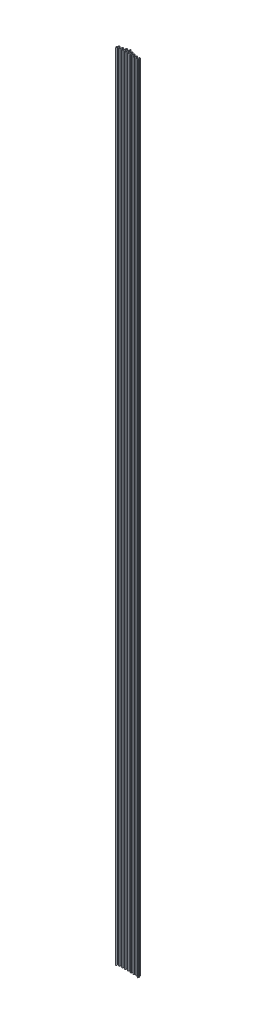
from build123d import *

# Parameters (mm, degrees)
BOSS_EXTRUDE1_DEPTH = 3505.2
CUT_EXTRUDE1_DEPTH  = 3506.2
BOSS_EXTRUDE2_DEPTH = 3505.2
FILLET1_R           = 0.508


with BuildPart() as part:
    # Sketch1 → Boss-Extrude1 (new body)
    with BuildSketch(Plane(origin=(0, 0, 0), x_dir=(1, 0, 0), z_dir=(0, 1, 0))):
        with BuildLine():
            Line((1.486485486, 1.007746677), (3.990499229, 7.290402101))
            ThreePointArc((3.990499229, 7.290402101), (6.35, 8.89), (8.709500771, 7.290402101))
            Line((8.709500771, 7.290402101), (11.213514514, 1.007746677))
            ThreePointArc((11.213514514, 1.007746677), (12.784145017, 0.002213875), (14.240485976, 1.167137652))
            Line((14.240485976, 1.167137652), (16.604784165, 9.577400553))
            ThreePointArc((16.604784165, 9.577400553), (19.05, 11.43), (21.495215835, 9.577400553))
            Line((21.495215835, 9.577400553), (23.859514024, 1.167137652))
            ThreePointArc((23.859514024, 1.167137652), (25.467277455, 0.001414904), (26.971422384, 1.298087881))
            Line((26.971422384, 1.298087881), (29.255678756, 13.179543046))
            ThreePointArc((29.255678756, 13.179543046), (31.75, 15.24), (34.244321244, 13.179543046))
            Line((34.244321244, 13.179543046), (36.528577616, 1.298087881))
            ThreePointArc((36.528577616, 1.298087881), (38.136521885, 0.00041683), (39.683572077, 1.370114107))
            Line((39.683572077, 1.370114107), (41.936393529, 16.875215703))
            ThreePointArc((41.936393529, 16.875215703), (44.45, 19.05), (46.963606471, 16.875215703))
            Line((46.963606471, 16.875215703), (49.216427923, 1.370114107))
            ThreePointArc((49.216427923, 1.370114107), (50.763478115, 0.00041683), (52.371422384, 1.298087881))
            Line((52.371422384, 1.298087881), (54.655678756, 13.179543046))
            ThreePointArc((54.655678756, 13.179543046), (57.15, 15.24), (59.644321244, 13.179543046))
            Line((59.644321244, 13.179543046), (61.928577616, 1.298087881))
            ThreePointArc((61.928577616, 1.298087881), (63.432722545, 0.001414904), (65.040485976, 1.167137652))
            Line((65.040485976, 1.167137652), (67.404784165, 9.577400553))
            ThreePointArc((67.404784165, 9.577400553), (69.85, 11.43), (72.295215835, 9.577400553))
            Line((72.295215835, 9.577400553), (74.659514024, 1.167137652))
            ThreePointArc((74.659514024, 1.167137652), (76.115854983, 0.002213875), (77.686485486, 1.007746677))
            Line((77.686485486, 1.007746677), (80.190499229, 7.290402101))
            ThreePointArc((80.190499229, 7.290402101), (82.55, 8.89), (84.909500771, 7.290402101))
            Line((84.909500771, 7.290402101), (87.413514514, 1.007746677))
            ThreePointArc((87.413514514, 1.007746677), (88.9, 0), (90.386485486, 1.007746677))
            Line((90.386485486, 1.007746677), (92.890499229, 7.290402101))
            ThreePointArc((92.890499229, 7.290402101), (95.25, 8.89), (97.609500771, 7.290402101))
            Line((97.609500771, 7.290402101), (100.113514514, 1.007746677))
            ThreePointArc((100.113514514, 1.007746677), (100.702058957, 0.275684268), (101.6, 0))
            Line((101.6, 0), (101.6, -1.524))
            ThreePointArc((101.6, -1.524), (99.846877012, -0.985759286), (98.697814051, 0.443505416))
            Line((98.697814051, 0.443505416), (96.193800308, 6.72616084))
            ThreePointArc((96.193800308, 6.72616084), (95.25, 7.366), (94.306199692, 6.72616084))
            Line((94.306199692, 6.72616084), (91.802185949, 0.443505416))
            ThreePointArc((91.802185949, 0.443505416), (88.9, -1.524), (85.997814051, 0.443505416))
            Line((85.997814051, 0.443505416), (83.493800308, 6.72616084))
            ThreePointArc((83.493800308, 6.72616084), (82.55, 7.366), (81.606199692, 6.72616084))
            Line((81.606199692, 6.72616084), (79.102185949, 0.443505416))
            ThreePointArc((79.102185949, 0.443505416), (76.035716871, -1.519677673), (73.192384523, 0.75469732))
            Line((73.192384523, 0.75469732), (70.828086334, 9.164960221))
            ThreePointArc((70.828086334, 9.164960221), (69.85, 9.906), (68.871913666, 9.164960221))
            Line((68.871913666, 9.164960221), (66.507615477, 0.75469732))
            ThreePointArc((66.507615477, 0.75469732), (63.368648778, -1.521237569), (60.43198487, 1.010362054))
            Line((60.43198487, 1.010362054), (58.147728498, 12.891817218))
            ThreePointArc((58.147728498, 12.891817218), (57.15, 13.716), (56.152271502, 12.891817218))
            Line((56.152271502, 12.891817218), (53.86801513, 1.010362054))
            ThreePointArc((53.86801513, 1.010362054), (50.728695368, -1.52318619), (47.708264041, 1.150984685))
            Line((47.708264041, 1.150984685), (45.455442588, 16.656086281))
            ThreePointArc((45.455442588, 16.656086281), (44.45, 17.526), (43.444557412, 16.656086281))
            Line((43.444557412, 16.656086281), (41.191735959, 1.150984685))
            ThreePointArc((41.191735959, 1.150984685), (38.171304632, -1.52318619), (35.03198487, 1.010362054))
            Line((35.03198487, 1.010362054), (32.747728498, 12.891817218))
            ThreePointArc((32.747728498, 12.891817218), (31.75, 13.716), (30.752271502, 12.891817218))
            Line((30.752271502, 12.891817218), (28.46801513, 1.010362054))
            ThreePointArc((28.46801513, 1.010362054), (25.531351222, -1.521237569), (22.392384523, 0.75469732))
            Line((22.392384523, 0.75469732), (20.028086334, 9.164960221))
            ThreePointArc((20.028086334, 9.164960221), (19.05, 9.906), (18.071913666, 9.164960221))
            Line((18.071913666, 9.164960221), (15.707615477, 0.75469732))
            ThreePointArc((15.707615477, 0.75469732), (12.864283129, -1.519677673), (9.797814051, 0.443505416))
            Line((9.797814051, 0.443505416), (7.293800308, 6.72616084))
            ThreePointArc((7.293800308, 6.72616084), (6.35, 7.366), (5.406199692, 6.72616084))
            Line((5.406199692, 6.72616084), (2.902185949, 0.443505416))
            ThreePointArc((2.902185949, 0.443505416), (1.753122988, -0.985759286), (0, -1.524))
            Line((0, -1.524), (0, 0))
            ThreePointArc((0, 0), (0.897941043, 0.275684268), (1.486485486, 1.007746677))
        make_face()
    extrude(amount=-BOSS_EXTRUDE1_DEPTH)

    # Sketch3 → Cut-Extrude1 (cut, through all)
    with BuildSketch(Plane(origin=(0, 0, 0), x_dir=(1, 0, 0), z_dir=(0, 1, 0))):
        Polygon((0, -0.762), (0, -1.524), (0.277345319, -1.524), align=None)
        Polygon((101.6, -0.762), (101.6, -1.524), (101.322654681, -1.524), align=None)
    extrude(amount=-CUT_EXTRUDE1_DEPTH, mode=Mode.SUBTRACT)

    # Sketch4 → Boss-Extrude2 (add, through all)
    with BuildSketch(Plane(origin=(0, 0, 0), x_dir=(1, 0, 0), z_dir=(0, 1, 0))):
        with BuildLine():
            Line((2.902185949, 0.443505416), (3.015459403, 0.727712357))
            ThreePointArc((3.015459403, 0.727712357), (3.040890247, 0.106552231), (3.520551169, -0.288937377))
            ThreePointArc((3.520551169, -0.288937377), (5.395968613, -3.748882593), (1.866026726, -5.488975049))
            ThreePointArc((1.866026726, -5.488975049), (1.726414147, -5.400370737), (1.63748848, -5.260962624))
            Line((1.63748848, -5.260962624), (1.411043325, -4.638809675))
            ThreePointArc((1.411043325, -4.638809675), (1.456969285, -4.289967378), (1.769066214, -4.1275))
            Line((1.769066214, -4.1275), (2.794, -4.1275))
            ThreePointArc((2.794, -4.1275), (4.0005, -2.921), (2.794, -1.7145))
            Line((2.794, -1.7145), (0.346681648, -1.7145))
            Line((0.346681648, -1.7145), (0.272995808, -1.512049818))
            ThreePointArc((0.272995808, -1.512049818), (1.864535831, -0.90661706), (2.902185949, 0.443505416))
        make_face()
        with BuildLine():
            Line((101.253318352, -1.7145), (101.327004192, -1.512049818))
            ThreePointArc((101.327004192, -1.512049818), (99.735464169, -0.90661706), (98.697814051, 0.443505416))
            Line((98.697814051, 0.443505416), (98.584540597, 0.727712357))
            ThreePointArc((98.584540597, 0.727712357), (98.559109753, 0.106552231), (98.079448831, -0.288937377))
            ThreePointArc((98.079448831, -0.288937377), (96.204031387, -3.748882593), (99.733973274, -5.488975049))
            ThreePointArc((99.733973274, -5.488975049), (99.873585853, -5.400370737), (99.96251152, -5.260962624))
            Line((99.96251152, -5.260962624), (100.188956675, -4.638809675))
            ThreePointArc((100.188956675, -4.638809675), (100.143030715, -4.289967378), (99.830933786, -4.1275))
            Line((99.830933786, -4.1275), (98.806, -4.1275))
            ThreePointArc((98.806, -4.1275), (97.5995, -2.921), (98.806, -1.7145))
            Line((98.806, -1.7145), (101.253318352, -1.7145))
        make_face()
    extrude(amount=-BOSS_EXTRUDE2_DEPTH)

    # Fillet1
    fillet1_edges = [part.edges().sort_by_distance(p)[0] for p in [
        (0.346681648, -1752.6, 1.7145),
        (101.253318352, -1752.6, 1.7145),
    ]]
    fillet(fillet1_edges, radius=FILLET1_R)


solid = part.part
